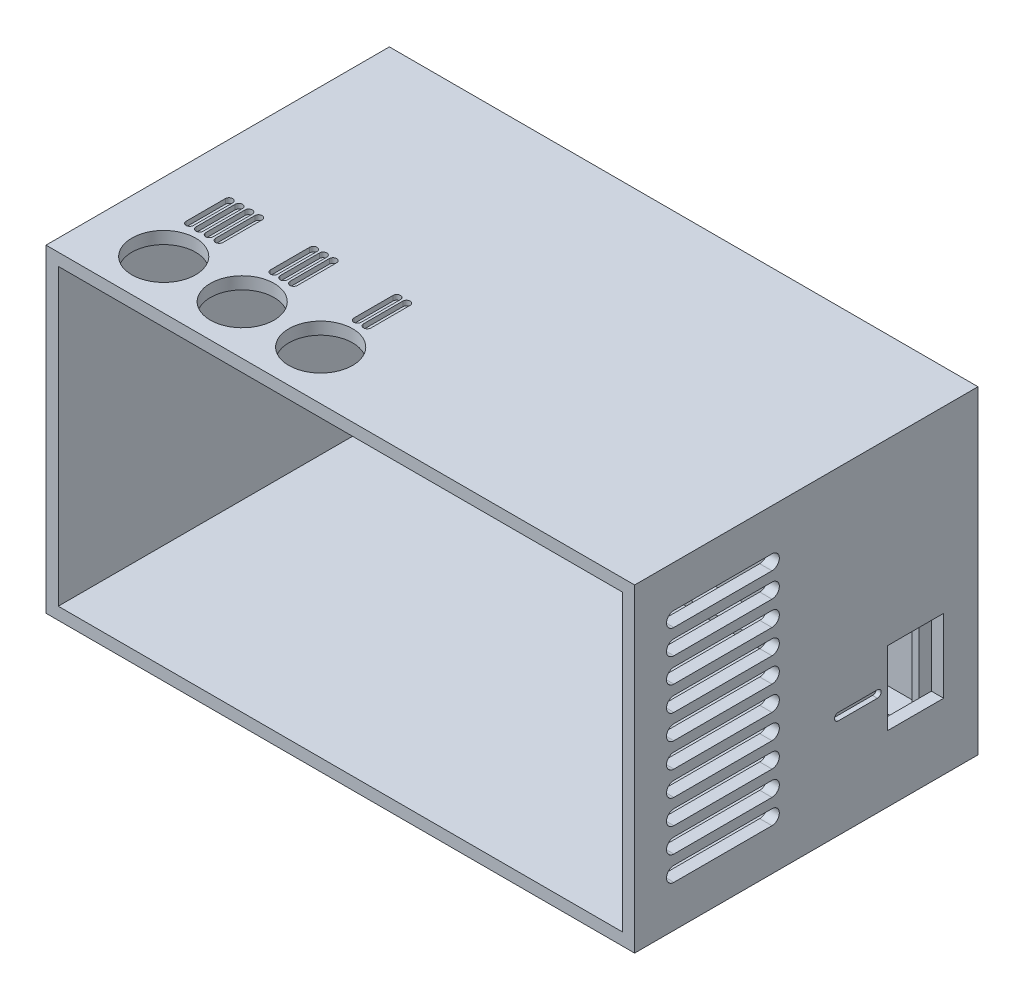
from build123d import *

# Parameters (mm, degrees)
BOSS_EXTRUDE1_DEPTH            = 5
SKETCH2_W                      = 5
SKETCH2_H                      = 39
BOSS_EXTRUDE2_DEPTH            = 103
SKETCH3_W                      = 117.5
SKETCH3_H                      = 67.5
BOSS_EXTRUDE3_DEPTH            = 18
SKETCH4_W                      = 2.5
SKETCH4_H                      = 67.5
BOSS_EXTRUDE4_DEPTH            = 39
SKETCH5_W                      = 117.5
SKETCH5_H                      = 67.5
BOSS_EXTRUDE5_DEPTH            = 8
CUT_EXTRUDE1_DEPTH             = 4
SKETCH7_W                      = 117.5
SKETCH7_H                      = 65
BOSS_EXTRUDE6_DEPTH            = 2.5
SKETCH8_W                      = 115
SKETCH8_H                      = 67.5
CUT_EXTRUDE2_DEPTH             = 1.5
CUT_EXTRUDE3_DEPTH             = 14
SKETCH10_W                     = 115
SKETCH10_H                     = 67.5
CUT_EXTRUDE4_DEPTH             = 1.5
SKETCH11_W                     = 70
SKETCH11_H                     = 65
BOSS_EXTRUDE7_DEPTH            = 2.5
CUT_EXTRUDE5_DEPTH             = 1.5
CUT_EXTRUDE6_DEPTH             = 3.5
CUT_EXTRUDE7_DEPTH             = 3.5
CUT_EXTRUDE8_DEPTH             = 3.5
CUT_EXTRUDE9_DEPTH             = 3.5
CUT_EXTRUDE10_DEPTH            = 3.5
CUT_EXTRUDE11_DEPTH            = 3.5
CUT_EXTRUDE12_DEPTH            = 3.5
CUT_EXTRUDE13_DEPTH            = 3.5
CUT_EXTRUDE14_DEPTH            = 3.5
CUT_EXTRUDE15_DEPTH            = 3.5
CUT_EXTRUDE16_DEPTH            = 3.5
CUT_EXTRUDE17_REACH            = 122
SKETCH24_W                     = 11.5
SKETCH24_H                     = 15
BOSS_EXTRUDE8_DEPTH            = 3.5
BOSS_EXTRUDE9_DEPTH            = 3.5
BOSS_EXTRUDE10_DEPTH           = 3.5
DRAFT1_ANGLE                   = 45
F_3_0_3_DIAMETER_HOLE1_D       = 3
F_3_0_3_DIAMETER_HOLE1_DEPTH   = 70
F_3_0_3_DIAMETER_HOLE2_D       = 3
F_3_0_3_DIAMETER_HOLE2_DEPTH   = 6
F_13_0_13_DIAMETER_HOLE1_D     = 13
F_13_0_13_DIAMETER_HOLE1_DEPTH = 2.5
CUT_EXTRUDE18_DEPTH            = 1
CUT_EXTRUDE19_DEPTH            = 1


with BuildPart() as part:
    # Sketch1 → Boss-Extrude1 (new body)
    with BuildSketch(Plane(origin=(0, 0, 2.5), x_dir=(-1, 0, 0), z_dir=(0, 0, -1))):
        Polygon((-12.5, 57), (-12.5, 18), (-10, 20.5), (-10, 54.5), align=None)
    extrude(amount=-BOSS_EXTRUDE1_DEPTH)

    # Sketch2 → Boss-Extrude2 (add)
    with BuildSketch(Plane(origin=(12.5, 0, 0), x_dir=(0, 0, -1), z_dir=(1, 0, 0))):
        with Locations((-5, 37.5)):
            Rectangle(SKETCH2_W, SKETCH2_H)
    extrude(amount=BOSS_EXTRUDE2_DEPTH)

    # Sketch3 → Boss-Extrude3 (add)
    with BuildSketch(Plane.XZ.offset(-18)):
        with Locations((58.75, 36.25)):
            Rectangle(SKETCH3_W, SKETCH3_H)
    extrude(amount=BOSS_EXTRUDE3_DEPTH)

    # Sketch4 → Boss-Extrude4 (add)
    with BuildSketch(Plane(origin=(0, 18, 0), x_dir=(-1, 0, 0), z_dir=(0, 1, 0))):
        with Locations((-1.25, 36.25)):
            Rectangle(SKETCH4_W, SKETCH4_H)
    extrude(amount=BOSS_EXTRUDE4_DEPTH)

    # Sketch5 → Boss-Extrude5 (add)
    with BuildSketch(Plane(origin=(0, 57, 0), x_dir=(-1, 0, 0), z_dir=(0, 1, 0))):
        with Locations((-58.75, 36.25)):
            Rectangle(SKETCH5_W, SKETCH5_H)
    extrude(amount=BOSS_EXTRUDE5_DEPTH)

    # Sketch6 → Cut-Extrude1 (cut)
    with BuildSketch(Plane.XZ.offset(-57)):
        Polygon((115.5, 7.5), (115.5, 2.5), (117.5, 2.5), (117.5, 70), (2.5, 70), (2.5, 2.5), (12.5, 2.5), (12.5, 7.5), align=None)
    extrude(amount=-CUT_EXTRUDE1_DEPTH, mode=Mode.SUBTRACT)

    # Sketch7 → Boss-Extrude6 (add)
    with BuildSketch(Plane(origin=(0, 0, 2.5), x_dir=(-1, 0, 0), z_dir=(0, 0, -1))):
        with Locations((-58.75, 32.5)):
            Rectangle(SKETCH7_W, SKETCH7_H)
    extrude(amount=BOSS_EXTRUDE6_DEPTH)

    # Sketch8 → Cut-Extrude2 (cut)
    with BuildSketch(Plane.XZ.offset(-61)):
        with Locations((60, 36.25)):
            Rectangle(SKETCH8_W, SKETCH8_H)
    extrude(amount=-CUT_EXTRUDE2_DEPTH, mode=Mode.SUBTRACT)

    # Sketch9 → Cut-Extrude3 (cut)
    with BuildSketch(Plane(origin=(0, 18, 0), x_dir=(-1, 0, 0), z_dir=(0, 1, 0))):
        Polygon((-115.5, 2.5), (-115.5, 7.5), (-12.5, 7.5), (-12.5, 2.5), (-2.5, 2.5), (-2.5, 70), (-117.5, 70), (-117.5, 2.5), align=None)
    extrude(amount=-CUT_EXTRUDE3_DEPTH, mode=Mode.SUBTRACT)

    # Sketch10 → Cut-Extrude4 (cut)
    with BuildSketch(Plane(origin=(0, 4, 0), x_dir=(-1, 0, 0), z_dir=(0, 1, 0))):
        with Locations((-60, 36.25)):
            Rectangle(SKETCH10_W, SKETCH10_H)
    extrude(amount=-CUT_EXTRUDE4_DEPTH, mode=Mode.SUBTRACT)

    # Sketch11 → Boss-Extrude7 (add)
    with BuildSketch(Plane(origin=(117.5, 0, 0), x_dir=(0, 0, -1), z_dir=(1, 0, 0))):
        with Locations((-35, 32.5)):
            Rectangle(SKETCH11_W, SKETCH11_H)
    extrude(amount=BOSS_EXTRUDE7_DEPTH)

    # Sketch12 → Cut-Extrude5 (cut)
    with BuildSketch(Plane.XY.offset(7.5)):
        Polygon((114, 5.5), (114, 59.5), (14, 59.5), (14, 56.5), (11.5, 54), (11.5, 21), (14, 21), (14, 5.5), align=None)
    extrude(amount=-CUT_EXTRUDE5_DEPTH, mode=Mode.SUBTRACT)

    # Sketch13 → Cut-Extrude6 (cut)
    with BuildSketch(Plane.XY.offset(6)):
        with BuildLine():
            Line((14, 21), (14, 5.5))
            Line((14, 5.5), (114, 5.5))
            Line((114, 5.5), (114, 59.5))
            Line((114, 59.5), (18, 59.5))
            Line((18, 59.5), (18, 58.5))
            ThreePointArc((18, 58.5), (16.618033989, 56.263932023), (14, 56.5))
            Line((14, 56.5), (11.5, 54))
            Line((11.5, 54), (11.5, 21))
            Line((11.5, 21), (14, 21))
        make_face()
    extrude(amount=-CUT_EXTRUDE6_DEPTH, mode=Mode.SUBTRACT)

    # Sketch14 → Cut-Extrude7 (cut, through all)
    with BuildSketch(Plane.ZY.offset(-117.5)):
        with BuildLine():
            Line((41.999982861, 53.5), (62, 53.5))
            ThreePointArc((62, 53.5), (63.5, 55), (62, 56.5))
            Line((62, 56.5), (41.999982861, 56.5))
            ThreePointArc((41.999982861, 56.5), (40.499982861, 55), (41.999982861, 53.5))
        make_face()
    extrude(amount=-CUT_EXTRUDE7_DEPTH, mode=Mode.SUBTRACT)

    # Sketch15 → Cut-Extrude8 (cut, through all)
    with BuildSketch(Plane.ZY.offset(-117.5)):
        with BuildLine():
            Line((41.999982861, 48.5), (62, 48.5))
            ThreePointArc((62, 48.5), (63.5, 50), (62, 51.5))
            Line((62, 51.5), (41.999982861, 51.5))
            ThreePointArc((41.999982861, 51.5), (40.499982861, 50), (41.999982861, 48.5))
        make_face()
    extrude(amount=-CUT_EXTRUDE8_DEPTH, mode=Mode.SUBTRACT)

    # Sketch16 → Cut-Extrude9 (cut, through all)
    with BuildSketch(Plane.ZY.offset(-117.5)):
        with BuildLine():
            Line((41.999982861, 43.5), (62, 43.5))
            ThreePointArc((62, 43.5), (63.5, 45), (62, 46.5))
            Line((62, 46.5), (41.999982861, 46.5))
            ThreePointArc((41.999982861, 46.5), (40.499982861, 45), (41.999982861, 43.5))
        make_face()
    extrude(amount=-CUT_EXTRUDE9_DEPTH, mode=Mode.SUBTRACT)

    # Sketch17 → Cut-Extrude10 (cut, through all)
    with BuildSketch(Plane.ZY.offset(-117.5)):
        with BuildLine():
            Line((41.999982861, 38.5), (62, 38.5))
            ThreePointArc((62, 38.5), (63.5, 40), (62, 41.5))
            Line((62, 41.5), (41.999982861, 41.5))
            ThreePointArc((41.999982861, 41.5), (40.499982861, 40), (41.999982861, 38.5))
        make_face()
    extrude(amount=-CUT_EXTRUDE10_DEPTH, mode=Mode.SUBTRACT)

    # Sketch18 → Cut-Extrude11 (cut, through all)
    with BuildSketch(Plane.ZY.offset(-117.5)):
        with BuildLine():
            Line((41.999982861, 33.5), (62, 33.5))
            ThreePointArc((62, 33.5), (63.5, 35), (62, 36.5))
            Line((62, 36.5), (41.999982861, 36.5))
            ThreePointArc((41.999982861, 36.5), (40.499982861, 35), (41.999982861, 33.5))
        make_face()
    extrude(amount=-CUT_EXTRUDE11_DEPTH, mode=Mode.SUBTRACT)

    # Sketch19 → Cut-Extrude12 (cut, through all)
    with BuildSketch(Plane.ZY.offset(-117.5)):
        with BuildLine():
            Line((41.999982861, 28.5), (62, 28.5))
            ThreePointArc((62, 28.5), (63.5, 30), (62, 31.5))
            Line((62, 31.5), (41.999982861, 31.5))
            ThreePointArc((41.999982861, 31.5), (40.499982861, 30), (41.999982861, 28.5))
        make_face()
    extrude(amount=-CUT_EXTRUDE12_DEPTH, mode=Mode.SUBTRACT)

    # Sketch20 → Cut-Extrude13 (cut, through all)
    with BuildSketch(Plane.ZY.offset(-117.5)):
        with BuildLine():
            Line((41.999982861, 23.5), (62, 23.5))
            ThreePointArc((62, 23.5), (63.5, 25), (62, 26.5))
            Line((62, 26.5), (41.999982861, 26.5))
            ThreePointArc((41.999982861, 26.5), (40.499982861, 25), (41.999982861, 23.5))
        make_face()
    extrude(amount=-CUT_EXTRUDE13_DEPTH, mode=Mode.SUBTRACT)

    # Sketch21 → Cut-Extrude14 (cut, through all)
    with BuildSketch(Plane.ZY.offset(-117.5)):
        with BuildLine():
            Line((41.999982861, 18.5), (62, 18.5))
            ThreePointArc((62, 18.5), (63.5, 20), (62, 21.5))
            Line((62, 21.5), (41.999982861, 21.5))
            ThreePointArc((41.999982861, 21.5), (40.499982861, 20), (41.999982861, 18.5))
        make_face()
    extrude(amount=-CUT_EXTRUDE14_DEPTH, mode=Mode.SUBTRACT)

    # Sketch22 → Cut-Extrude15 (cut, through all)
    with BuildSketch(Plane.ZY.offset(-117.5)):
        with BuildLine():
            Line((62, 11.5), (41.999982861, 11.5))
            ThreePointArc((41.999982861, 11.5), (40.499982861, 10), (41.999982861, 8.5))
            Line((41.999982861, 8.5), (62, 8.5))
            ThreePointArc((62, 8.5), (63.5, 10), (62, 11.5))
        make_face()
    extrude(amount=-CUT_EXTRUDE15_DEPTH, mode=Mode.SUBTRACT)

    # Sketch23 → Cut-Extrude16 (cut, through all)
    with BuildSketch(Plane.ZY.offset(-117.5)):
        with BuildLine():
            Line((41.999982861, 13.5), (62, 13.5))
            ThreePointArc((62, 13.5), (63.5, 15), (62, 16.5))
            Line((62, 16.5), (41.999982861, 16.5))
            ThreePointArc((41.999982861, 16.5), (40.499982861, 15), (41.999982861, 13.5))
        make_face()
    extrude(amount=-CUT_EXTRUDE16_DEPTH, mode=Mode.SUBTRACT)

    # Sketch24 → Cut-Extrude17 (cut, up to next)
    with BuildSketch(Plane(origin=(120, 0, 0), x_dir=(0, 0, -1), z_dir=(1, 0, 0)), mode=Mode.PRIVATE) as cut_extrude17_sk1:
        with Locations((-12.75, 21)):
            Rectangle(SKETCH24_W, SKETCH24_H)
    cut_extrude17_tool1 = extrude(cut_extrude17_sk1.sketch, amount=-CUT_EXTRUDE17_REACH, mode=Mode.PRIVATE) & part.part
    add(cut_extrude17_tool1.solids().sort_by_distance((120, 21, 12.75))[0], mode=Mode.SUBTRACT)

    # Sketch25 → Boss-Extrude8 (add)
    with BuildSketch(Plane.XY.offset(2.5)):
        with BuildLine():
            Line((102, 8), (102, 5.5))
            Line((102, 5.5), (97, 5.5))
            Line((97, 5.5), (97, 8))
            ThreePointArc((97, 8), (99.5, 10.5), (102, 8))
        make_face()
    extrude(amount=BOSS_EXTRUDE8_DEPTH)

    # Sketch26 → Boss-Extrude9 (add)
    with BuildSketch(Plane.XY.offset(2.5)):
        with BuildLine():
            Line((25, 8), (25, 5.5))
            Line((25, 5.5), (20, 5.5))
            Line((20, 5.5), (20, 8))
            ThreePointArc((20, 8), (22.5, 10.5), (25, 8))
        make_face()
    extrude(amount=BOSS_EXTRUDE9_DEPTH)

    # Sketch27 → Boss-Extrude10 (add)
    with BuildSketch(Plane.XY.offset(2.5)):
        with BuildLine():
            Line((97, 57), (97, 59.5))
            Line((97, 59.5), (102, 59.5))
            Line((102, 59.5), (102, 57))
            ThreePointArc((102, 57), (99.5, 54.5), (97, 57))
        make_face()
    extrude(amount=BOSS_EXTRUDE10_DEPTH)

    # Draft1
    draft1_faces = [part.faces().sort_by_distance(p)[0] for p in [
        (12.75, 21, 5),
    ]]
    draft(draft1_faces, Plane(origin=(11.5, 54, 6), x_dir=(0, 0, 1), z_dir=(1, 0, 0)), DRAFT1_ANGLE)

    # Ø3.0 (3) Diameter Hole1
    with Locations(Plane(origin=(0, 0, 0), x_dir=(-1, 0, 0), z_dir=(0, 0, -1))):
        with Locations((-22.5, 8)):
            Hole(F_3_0_3_DIAMETER_HOLE1_D / 2, depth=F_3_0_3_DIAMETER_HOLE1_DEPTH)

    # Ø3.0 (3) Diameter Hole2
    with Locations(Plane(origin=(0, 0, 0), x_dir=(-1, 0, 0), z_dir=(0, 0, -1))):
        with Locations((-99.5, 57)):
            Hole(F_3_0_3_DIAMETER_HOLE2_D / 2, depth=F_3_0_3_DIAMETER_HOLE2_DEPTH)

    # Ø13.0 (13) Diameter Hole1
    with Locations(Plane(origin=(0, 65, 0), x_dir=(1, 0, 0), z_dir=(0, 1, 0))):
        with Locations((14, -60), (46, -60), (30, -60)):
            Hole(F_13_0_13_DIAMETER_HOLE1_D / 2, depth=F_13_0_13_DIAMETER_HOLE1_DEPTH)

    # Sketch36 → Cut-Extrude18 (cut)
    with BuildSketch(Plane(origin=(120, 0, 0), x_dir=(0, 0, -1), z_dir=(1, 0, 0))):
        with BuildLine():
            Line((-28.5, 21.75), (-20.5, 21.75))
            ThreePointArc((-20.5, 21.75), (-19.75, 21), (-20.5, 20.25))
            Line((-20.5, 20.25), (-28.5, 20.25))
            ThreePointArc((-28.5, 20.25), (-29.25, 21), (-28.5, 21.75))
        make_face()
    extrude(amount=-CUT_EXTRUDE18_DEPTH, mode=Mode.SUBTRACT)

    # Sketch37 → Cut-Extrude19 (cut)
    with BuildSketch(Plane(origin=(0, 65, 0), x_dir=(1, 0, 0), z_dir=(0, 1, 0))):
        with BuildLine():
            Line((45.75, -43.5), (45.75, -51.5))
            ThreePointArc((45.75, -51.5), (45, -52.25), (44.25, -51.5))
            Line((44.25, -51.5), (44.25, -43.5))
            ThreePointArc((44.25, -43.5), (45, -42.75), (45.75, -43.5))
        make_face()
        with BuildLine():
            Line((47.75, -43.5), (47.75, -51.5))
            ThreePointArc((47.75, -51.5), (47, -52.25), (46.25, -51.5))
            Line((46.25, -51.5), (46.25, -43.5))
            ThreePointArc((46.25, -43.5), (47, -42.75), (47.75, -43.5))
        make_face()
        with BuildLine():
            Line((28.75, -43.5), (28.75, -51.5))
            ThreePointArc((28.75, -51.5), (28, -52.25), (27.25, -51.5))
            Line((27.25, -51.5), (27.25, -43.5))
            ThreePointArc((27.25, -43.5), (28, -42.75), (28.75, -43.5))
        make_face()
        with BuildLine():
            Line((30.75, -43.5), (30.75, -51.5))
            ThreePointArc((30.75, -51.5), (30, -52.25), (29.25, -51.5))
            Line((29.25, -51.5), (29.25, -43.5))
            ThreePointArc((29.25, -43.5), (30, -42.75), (30.75, -43.5))
        make_face()
        with BuildLine():
            Line((32.75, -43.5), (32.75, -51.5))
            ThreePointArc((32.75, -51.5), (32, -52.25), (31.25, -51.5))
            Line((31.25, -51.5), (31.25, -43.5))
            ThreePointArc((31.25, -43.5), (32, -42.75), (32.75, -43.5))
        make_face()
        with BuildLine():
            Line((11.566696277, -43.502585149), (11.566696277, -51.502585149))
            ThreePointArc((11.566696277, -51.502585149), (10.816696277, -52.252585149), (10.066696277, -51.502585149))
            Line((10.066696277, -51.502585149), (10.066696277, -43.502585149))
            ThreePointArc((10.066696277, -43.502585149), (10.816696277, -42.752585149), (11.566696277, -43.502585149))
        make_face()
        with BuildLine():
            Line((13.566696277, -43.502585149), (13.566696277, -51.502585149))
            ThreePointArc((13.566696277, -51.502585149), (12.816696277, -52.252585149), (12.066696277, -51.502585149))
            Line((12.066696277, -51.502585149), (12.066696277, -43.502585149))
            ThreePointArc((12.066696277, -43.502585149), (12.816696277, -42.752585149), (13.566696277, -43.502585149))
        make_face()
        with BuildLine():
            Line((15.566696277, -43.502585149), (15.566696277, -51.502585149))
            ThreePointArc((15.566696277, -51.502585149), (14.816696277, -52.252585149), (14.066696277, -51.502585149))
            Line((14.066696277, -51.502585149), (14.066696277, -43.502585149))
            ThreePointArc((14.066696277, -43.502585149), (14.816696277, -42.752585149), (15.566696277, -43.502585149))
        make_face()
        with BuildLine():
            Line((17.566696277, -43.502585149), (17.566696277, -51.502585149))
            ThreePointArc((17.566696277, -51.502585149), (16.816696277, -52.252585149), (16.066696277, -51.502585149))
            Line((16.066696277, -51.502585149), (16.066696277, -43.502585149))
            ThreePointArc((16.066696277, -43.502585149), (16.816696277, -42.752585149), (17.566696277, -43.502585149))
        make_face()
    extrude(amount=-CUT_EXTRUDE19_DEPTH, mode=Mode.SUBTRACT)


solid = part.part
